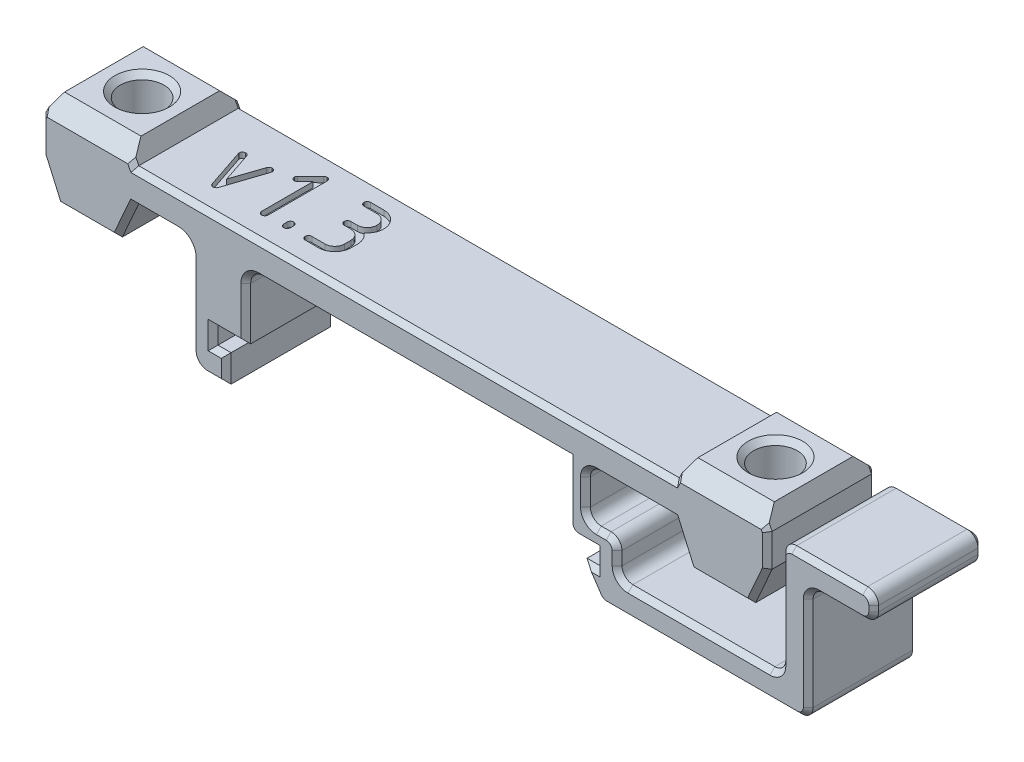
from build123d import *

# Parameters (mm, degrees)
MAIN_BODY_DEPTH         = 5
BOSS_EXTRUDE1_DEPTH     = 5
SKETCH3_R               = 2
CUT_HOLES_DEPTH         = 47.577891751
CUT_EXTRUDE2_DEPTH      = 45.544921147
CUT_EXTRUDE2_DEPTH_BACK = 45.544921147
SKETCH7_W               = 2.9
SKETCH7_H               = 4.4
FILLET_LOWER_EXT_R      = 1.5
FILLET_LOWER_INT_R      = 1.2
FILLET2_R               = 1
CHAMF_FACE_SIZE         = 0.45
CUT_VERSION_DEPTH       = 0.5
CHAMFER1_SIZE           = 0.5
CUT_EXTRUDE3_DEPTH      = 45.544921147


with BuildPart() as part:
    # Sketch1 → main_body (new, symmetric)
    with BuildSketch(Plane.XY):
        Polygon((-17.5, 0), (-17.5, -1.6), (-16.3, -1.6), (-16.3, -4.1), (-19.5, -4.1), (-19.5, 6), (-32.5, 6), (-32.5, 9), (32.5, 9), (32.5, 6), (19.5, 6), (19.5, -1.6), (34.5, -1.6), (34.5, 9), (43, 9), (43, 6.5), (37, 6.5), (37, -4.1), (18, -4.1), (16.3, -1.6), (17.5, -1.6), (17.5, 0), (15, 0), (15, 6), (-14.5, 6), (-14.5, 0), align=None)
    extrude(amount=MAIN_BODY_DEPTH, both=True)

    # Sketch6 → Boss-Extrude1 (add, symmetric)
    with BuildSketch(Plane.XY):
        Polygon((-33.25, 6), (-31.75, 2.6), (-26.25, 2.6), (-24.75, 6), (-24.75, 9), (-25.5, 10.5), (-32.5, 10.5), (-33.25, 9), align=None)
    boss_extrude1 = extrude(amount=BOSS_EXTRUDE1_DEPTH, both=True)

    # Sketch3 → cut_Holes (cut, through all)
    with BuildSketch(Plane(origin=(0, 0, -9.5), x_dir=(1, 0, 0), z_dir=(0, -1, 0))):
        with Locations((-29, 9.5)):
            Circle(SKETCH3_R)
    cut_holes = extrude(amount=-CUT_HOLES_DEPTH, mode=Mode.SUBTRACT)

    # Mirror1: Boss-Extrude1, cut_Holes across plane
    add(boss_extrude1.mirror(Plane(origin=(0, 0, 0), x_dir=(0, 0, 1), z_dir=(1, 0, 0))))
    add(cut_holes.mirror(Plane(origin=(0, 0, 0), x_dir=(0, 0, 1), z_dir=(1, 0, 0))), mode=Mode.SUBTRACT)

    # Sketch7 → Cut-Extrude2 (cut, two sides: drawn at the far end of the back side and taken through both)
    with BuildSketch(Plane.XY.offset(-CUT_EXTRUDE2_DEPTH_BACK)):
        with Locations((18.05, 3.8)):
            Rectangle(SKETCH7_W, SKETCH7_H)
    extrude(amount=CUT_EXTRUDE2_DEPTH + CUT_EXTRUDE2_DEPTH_BACK, mode=Mode.SUBTRACT)

    # fillet_lower_ext
    fillet_lower_ext_edges = [part.edges().sort_by_distance(p)[0] for p in [
        (-19.5, -4.1, 0),
    ]]
    fillet(fillet_lower_ext_edges, radius=FILLET_LOWER_EXT_R)

    # fillet_lower_int
    fillet_lower_int_edges = [part.edges().sort_by_distance(p)[0] for p in [
        (-14.5, 6, 0),
        (-19.5, 6, 0),
    ]]
    fillet(fillet_lower_int_edges, radius=FILLET_LOWER_INT_R)

    # Fillet2
    fillet2_edges = [part.edges().sort_by_distance(p)[0] for p in [
        (16.6, 1.6, 0),
        (16.6, 6, 0),
        (34.5, 9, 0),
        (34.5, -1.6, 0),
        (19.5, -1.6, 0),
        (19.5, 1.6, 0),
        (15, 0, 0),
        (37, 6.5, 0),
        (37, -4.1, 0),
        (18, -4.1, 0),
        (43, 6.5, 0),
        (43, 9, 0),
    ]]
    fillet(fillet2_edges, radius=FILLET2_R)

    # chamf_face
    chamf_face_edges = [part.edges().sort_by_distance(p)[0] for p in [
        (-19.5, 1.1, -5),
        (-17.15, -4.1, -5),
        (-16.3, -2.85, -5),
        (-16.9, -1.6, -5),
        (-17.5, -0.8, -5),
        (-16, 0, -5),
        (-14.5, 2.4, -5),
        (0.85, 6, -5),
        (15, 3.5, -5),
        (16.75, 0, -5),
        (17.5, -0.8, -5),
        (16.9, -1.6, -5),
        (17.001185407, -2.631155011, -5),
        (27.264648658, -4.1, -5),
        (19.5, 0, -5),
        (27.264648658, -4.1, 5),
        (17.001185407, -2.631155011, 5),
        (16.9, -1.6, 5),
        (17.5, -0.8, 5),
        (16.75, 0, 5),
        (15, 3.5, 5),
        (0.85, 6, 5),
        (-14.5, 2.4, 5),
        (-16, 0, 5),
        (-17.5, -0.8, 5),
        (-16.9, -1.6, 5),
        (-16.3, -2.85, 5),
        (-17.15, -4.1, 5),
        (-19.5, 1.1, 5),
        (19.5, 0, 5),
        (-19.060660172, -3.660660172, 5),
        (-19.060660172, -3.660660172, -5),
        (-14.148528137, 5.648528137, 5),
        (-14.148528137, 5.648528137, -5),
        (-22.725, 6, 5),
        (-25.5, 4.3, 5),
        (-29, 2.6, 5),
        (-32.5, 4.3, 5),
        (21.175, 6, 5),
        (32.5, 4.3, 5),
        (29, 2.6, 5),
        (25.5, 4.3, 5),
        (25.5, 4.3, -5),
        (29, 2.6, -5),
        (32.5, 4.3, -5),
        (21.175, 6, -5),
        (-32.5, 4.3, -5),
        (-29, 2.6, -5),
        (-25.5, 4.3, -5),
        (-22.725, 6, -5),
        (-32.875, 9.75, 5),
        (-29, 10.5, 5),
        (-25.125, 9.75, 5),
        (0, 9, 5),
        (25.125, 9.75, 5),
        (29, 10.5, 5),
        (32.875, 9.75, 5),
        (32.875, 9.75, -5),
        (29, 10.5, -5),
        (25.125, 9.75, -5),
        (0, 9, -5),
        (-25.125, 9.75, -5),
        (-29, 10.5, -5),
        (-32.875, 9.75, -5),
        (-33.25, 7.5, 5),
        (33.25, 7.5, 5),
        (33.25, 7.5, -5),
        (-33.25, 7.5, -5),
        (27, -1.6, 5),
        (34.5, 3.7, 5),
        (38.75, 9, 5),
        (43, 7.75, 5),
        (40, 6.5, 5),
        (37, 1.2, 5),
        (37, 1.2, -5),
        (40, 6.5, -5),
        (43, 7.75, -5),
        (38.75, 9, -5),
        (34.5, 3.7, -5),
        (27, -1.6, -5),
        (16.6, 3.8, 5),
        (18.05, 1.6, 5),
        (18.05, 1.6, -5),
        (16.6, 3.8, -5),
        (15.292893219, 0.292893219, 5),
        (16.892893219, 5.707106781, 5),
        (16.892893219, 1.892893219, 5),
        (19.207106781, 1.307106781, 5),
        (19.792893219, -1.307106781, 5),
        (34.207106781, -1.307106781, 5),
        (34.792893219, 8.707106781, 5),
        (42.707106781, 8.707106781, 5),
        (42.707106781, 6.792893219, 5),
        (37.292893219, 6.207106781, 5),
        (36.707106781, -3.807106781, 5),
        (18.061488606, -3.983829741, 5),
        (36.707106781, -3.807106781, -5),
        (37.292893219, 6.207106781, -5),
        (42.707106781, 6.792893219, -5),
        (42.707106781, 8.707106781, -5),
        (34.792893219, 8.707106781, -5),
        (34.207106781, -1.307106781, -5),
        (19.792893219, -1.307106781, -5),
        (19.207106781, 1.307106781, -5),
        (16.892893219, 1.892893219, -5),
        (16.892893219, 5.707106781, -5),
        (15.292893219, 0.292893219, -5),
        (18.061488606, -3.983829741, -5),
        (-19.851471863, 5.648528137, 5),
        (-19.851471863, 5.648528137, -5),
    ]]
    chamfer(chamf_face_edges, length=CHAMF_FACE_SIZE)

    # Sketch4 → cut_version (cut)
    with BuildSketch(Plane(origin=(0, 9, 0), x_dir=(1, 0, 0), z_dir=(0, 1, 0))):
        with BuildLine():
            add(Edge.make_bspline(
                [(-21.180476134, 1.074905685), (-21.178229692, 1.055475579), (-21.173879093, 1.017846026), (-21.161688752, 0.981990729), (-21.155792921, 0.964649396)],
                knots=[0, 0, 0, 0, 1.032704525, 2, 2, 2, 2], degree=3))
            Line((-21.155792921, 0.964649396), (-19.95821289, -2.616713742))
            add(Edge.make_bspline(
                [(-19.95821289, -2.616713742), (-19.945122381, -2.648127203), (-19.920205519, -2.707920514), (-19.852245155, -2.776643503), (-19.768521194, -2.823749577), (-19.704805806, -2.832181772), (-19.671646579, -2.836570116)],
                knots=[0, 0, 0, 0, 1.054683453, 2.007515722, 2.96305683, 4, 4, 4, 4], degree=3))
            add(Edge.make_bspline(
                [(-19.671646579, -2.836570116), (-19.636883169, -2.832254713), (-19.570839873, -2.824056339), (-19.484084239, -2.777440659), (-19.41591287, -2.707903707), (-19.390878095, -2.64831818), (-19.37774414, -2.617057921)],
                knots=[0, 0, 0, 0, 1.06836729, 2.029677035, 2.966312611, 4, 4, 4, 4], degree=3))
            Line((-19.37774414, -2.617057921), (-18.179609137, 0.965586658))
            add(Edge.make_bspline(
                [(-18.179609137, 0.965586658), (-18.175165622, 0.982665802), (-18.165880697, 1.01835344), (-18.164059576, 1.055195206), (-18.163109994, 1.074405494)],
                knots=[0, 0, 0, 0, 0.957146177, 2, 2, 2, 2], degree=3))
            add(Edge.make_bspline(
                [(-18.163109994, 1.074405494), (-18.164733377, 1.094475764), (-18.167875161, 1.133318403), (-18.186175558, 1.188545541), (-18.212592243, 1.239471456), (-18.25110866, 1.282952891), (-18.296384686, 1.319665958), (-18.347492654, 1.34864997), (-18.405776221, 1.364210818), (-18.445958207, 1.367713434), (-18.466768531, 1.369527445)],
                knots=[0, 0, 0, 0, 1.027789528, 1.989114056, 2.957849911, 3.946954469, 4.938684973, 5.935646619, 6.930867606, 8, 8, 8, 8], degree=3))
            add(Edge.make_bspline(
                [(-18.466768531, 1.369527445), (-18.499846403, 1.365007685), (-18.563213413, 1.356349216), (-18.648157394, 1.311071016), (-18.714802614, 1.240873743), (-18.740128103, 1.181186085), (-18.753353896, 1.15001525)],
                knots=[0, 0, 0, 0, 1.03692919, 1.986436811, 2.948451835, 4, 4, 4, 4], degree=3))
            Line((-18.753353896, 1.15001525), (-19.671613233, -1.58238757))
            Line((-19.671613233, -1.58238757), (-20.581988614, 1.150588087))
            add(Edge.make_bspline(
                [(-20.581988614, 1.150588087), (-20.59544029, 1.181576306), (-20.621338409, 1.241237019), (-20.689349611, 1.311524093), (-20.777309264, 1.356697902), (-20.843044194, 1.365094877), (-20.87774414, 1.369527445)],
                knots=[0, 0, 0, 0, 1.028913269, 1.980936724, 2.934183284, 4, 4, 4, 4], degree=3))
            add(Edge.make_bspline(
                [(-20.87774414, 1.369527445), (-20.897743404, 1.367694972), (-20.936718664, 1.364123785), (-20.993718481, 1.348424285), (-21.04461462, 1.319346986), (-21.09095554, 1.283043392), (-21.13053148, 1.239514385), (-21.158550939, 1.188871734), (-21.176563528, 1.133281068), (-21.179754091, 1.094463045), (-21.181402677, 1.074405494)],
                knots=[0, 0, 0, 0, 1.030543514, 2.008358934, 3.007991962, 4.018680577, 5.024181706, 6.005556065, 6.969456486, 8, 8, 8, 8], degree=3))
            Line((-21.181402677, 1.074405494), (-21.180476134, 1.074905685))
        make_face()
        with BuildLine():
            add(Edge.make_bspline(
                [(-16.638972227, 1.888665688), (-16.652972987, 1.874710807), (-16.680696441, 1.847078199), (-16.710474368, 1.795810047), (-16.727632283, 1.738054778), (-16.730922833, 1.697690205), (-16.732622189, 1.676844518)],
                knots=[0, 0, 0, 0, 0.992164211, 1.96462331, 2.948859839, 4, 4, 4, 4], degree=3))
            add(Edge.make_bspline(
                [(-16.732622189, 1.676844518), (-16.730982583, 1.655972744), (-16.727807729, 1.615557655), (-16.709839194, 1.558198421), (-16.683190497, 1.50569602), (-16.644579553, 1.461233708), (-16.600112944, 1.422596701), (-16.547601722, 1.396046709), (-16.490325151, 1.377710353), (-16.449846912, 1.375530242), (-16.428963653, 1.374405494)],
                knots=[0, 0, 0, 0, 1.0530203, 2.0390173, 3.01127151, 4.001099292, 4.990927074, 5.963181283, 6.949178283, 8, 8, 8, 8], degree=3))
            add(Edge.make_bspline(
                [(-16.428963653, 1.374405494), (-16.407279145, 1.376479493), (-16.365196389, 1.380504467), (-16.30599893, 1.399127939), (-16.252991635, 1.427412629), (-16.224003518, 1.453827921), (-16.209451457, 1.467088421)],
                knots=[0, 0, 0, 0, 1.06971459, 2.075976935, 3.034138695, 4, 4, 4, 4], degree=3))
            Line((-16.209451457, 1.467088421), (-15.513393435, 2.179439555))
            Line((-15.513393435, 2.179439555), (-15.513393435, -2.532622183))
            add(Edge.make_bspline(
                [(-15.513393435, -2.532622183), (-15.512151243, -2.553595292), (-15.509749357, -2.594148622), (-15.491554772, -2.651609659), (-15.464778743, -2.703612611), (-15.42760543, -2.748966042), (-15.383161366, -2.786700972), (-15.331855902, -2.81384126), (-15.275625191, -2.831742741), (-15.236012074, -2.834925823), (-15.215549018, -2.836570116)],
                knots=[0, 0, 0, 0, 1.064897874, 2.059072668, 3.039390689, 4.024276954, 5.022314302, 5.984364611, 6.958777708, 8, 8, 8, 8], degree=3))
            add(Edge.make_bspline(
                [(-15.215549018, -2.836570116), (-15.195101611, -2.834874744), (-15.155130709, -2.831560606), (-15.098330278, -2.81412534), (-15.046758765, -2.786658458), (-15.002140453, -2.74903438), (-14.965458394, -2.703236043), (-14.936413751, -2.652203257), (-14.920869107, -2.593899598), (-14.917364211, -2.553720439), (-14.915549018, -2.532911579)],
                knots=[0, 0, 0, 0, 1.038553346, 2.030179789, 2.989764092, 3.985243189, 4.967604913, 5.955148361, 6.940967594, 8, 8, 8, 8], degree=3))
            Line((-14.915549018, -2.532911579), (-14.915549018, 2.864107523))
            add(Edge.make_bspline(
                [(-14.915549018, 2.864107523), (-14.917412723, 2.884276544), (-14.921065093, 2.923802521), (-14.936389847, 2.981522331), (-14.965522014, 3.032461712), (-15.001748929, 3.078401203), (-15.047188141, 3.11463771), (-15.098283655, 3.142192757), (-15.155068403, 3.159918834), (-15.195094906, 3.162242472), (-15.215549018, 3.163429884)],
                knots=[0, 0, 0, 0, 1.033276339, 2.024949948, 3.018358012, 4.006553579, 4.994749146, 5.960032027, 6.957547333, 8, 8, 8, 8], degree=3))
            add(Edge.make_bspline(
                [(-15.215549018, 3.163429884), (-15.235998424, 3.162242575), (-15.275626754, 3.159941722), (-15.332169152, 3.142454949), (-15.381909564, 3.112567948), (-15.409139042, 3.08557452), (-15.422866092, 3.07196647)],
                knots=[0, 0, 0, 0, 1.049879887, 2.034532876, 3.009159723, 4, 4, 4, 4], degree=3))
            Line((-15.422866092, 3.07196647), (-16.638972227, 1.888665688))
        make_face()
        with BuildLine():
            add(Edge.make_bspline(
                [(-13.497056259, -2.521145192), (-13.495982099, -2.542277246), (-13.493892454, -2.583387053), (-13.475941144, -2.64152942), (-13.448654902, -2.694363881), (-13.410933087, -2.740056115), (-13.365563943, -2.778316986), (-13.313518492, -2.806964482), (-13.255254137, -2.824463441), (-13.214448803, -2.826826194), (-13.193597799, -2.82803353)],
                knots=[0, 0, 0, 0, 1.053795159, 2.050028647, 3.013195991, 4.009429478, 4.990006149, 5.962765968, 6.958999455, 8, 8, 8, 8], degree=3))
            add(Edge.make_bspline(
                [(-13.193597799, -2.82803353), (-13.172732509, -2.826876707), (-13.132289099, -2.824634423), (-13.074579668, -2.806682737), (-13.022844318, -2.778342006), (-12.977482987, -2.740049332), (-12.939763382, -2.694365373), (-12.912460696, -2.641529981), (-12.894651849, -2.583629929), (-12.892340066, -2.542799696), (-12.891158775, -2.521935969)],
                knots=[0, 0, 0, 0, 1.045213593, 2.025948432, 3.002645121, 3.987190297, 4.987455656, 5.954521048, 6.954786407, 8, 8, 8, 8], degree=3))
            Line((-12.891158775, -2.521935969), (-12.890139339, -2.22278153))
            add(Edge.make_bspline(
                [(-12.890139339, -2.22278153), (-12.891718256, -2.20123099), (-12.894786282, -2.159355715), (-12.91249375, -2.10001714), (-12.939080044, -2.04619233), (-12.977611837, -2.001383115), (-13.022878158, -1.964154607), (-13.074906494, -1.937414214), (-13.132250718, -1.919160982), (-13.172719447, -1.916969185), (-13.193597799, -1.915838408)],
                knots=[0, 0, 0, 0, 1.076562654, 2.091889952, 3.072719245, 4.052917712, 5.020200157, 5.982996012, 6.959400964, 8, 8, 8, 8], degree=3))
            add(Edge.make_bspline(
                [(-13.193597799, -1.915838408), (-13.214461887, -1.917019718), (-13.255292825, -1.919331536), (-13.313187815, -1.937140129), (-13.365530821, -1.964179756), (-13.410800766, -2.001376687), (-13.449351584, -2.046192455), (-13.475856894, -2.100023176), (-13.493911976, -2.159415947), (-13.496118499, -2.201469658), (-13.497256335, -2.223155482)],
                knots=[0, 0, 0, 0, 1.037498569, 2.03038068, 2.990307883, 3.954708309, 4.931986273, 5.909893183, 6.922195311, 8, 8, 8, 8], degree=3))
            Line((-13.497256335, -2.223155482), (-13.497056259, -2.521145192))
        make_face()
        with BuildLine():
            add(Edge.make_bspline(
                [(-10.028271722, 0.134360477), (-9.96637049, 0.130053792), (-9.846068702, 0.121683976), (-9.674241364, 0.071470496), (-9.51935378, -0.008517443), (-9.38519772, -0.118149917), (-9.273199343, -0.249335082), (-9.191879788, -0.401669705), (-9.138341017, -0.570104911), (-9.130530421, -0.689004927), (-9.126524628, -0.74998475)],
                knots=[0, 0, 0, 0, 1.058978584, 2.058069159, 3.037758071, 4.021657752, 5.003688209, 5.968206507, 6.9579614, 8, 8, 8, 8], degree=3))
            Line((-9.126524628, -0.74998475), (-9.126325743, -1.33592225))
            add(Edge.make_bspline(
                [(-9.126325743, -1.33592225), (-9.130385696, -1.397123472), (-9.138287906, -1.51624428), (-9.192094088, -1.685181029), (-9.273434943, -1.838579367), (-9.385146593, -1.971789808), (-9.518545447, -2.084425895), (-9.674547801, -2.16365083), (-9.846022141, -2.216099273), (-9.966779114, -2.223976899), (-10.028963653, -2.22803353)],
                knots=[0, 0, 0, 0, 1.041256597, 2.026680567, 2.993073191, 3.981435433, 4.969797675, 5.945199709, 6.941868068, 8, 8, 8, 8], degree=3))
            Line((-10.028963653, -2.22803353), (-11.233676162, -2.22803353))
            add(Edge.make_bspline(
                [(-11.233676162, -2.22803353), (-11.254613596, -2.229176859), (-11.295535389, -2.23141147), (-11.353060542, -2.24964611), (-11.406143357, -2.274872722), (-11.450613737, -2.312388371), (-11.489260154, -2.355599128), (-11.515847579, -2.406914912), (-11.53432882, -2.463376797), (-11.536414009, -2.503482762), (-11.537500238, -2.524374994)],
                knots=[0, 0, 0, 0, 1.060955747, 2.073616602, 3.043257174, 4.026868974, 5.007876325, 5.968681719, 6.941833903, 8, 8, 8, 8], degree=3))
            add(Edge.make_bspline(
                [(-11.537500238, -2.524374994), (-11.536324954, -2.545243955), (-11.534024927, -2.586084432), (-11.516131744, -2.643910995), (-11.489282847, -2.696735901), (-11.45068042, -2.741213713), (-11.406202609, -2.779816139), (-11.353377703, -2.806665037), (-11.29555114, -2.824558219), (-11.254710663, -2.826858246), (-11.233841701, -2.82803353)],
                knots=[0, 0, 0, 0, 1.045974665, 2.046968367, 3.014737927, 4, 4.985262073, 5.953031633, 6.954025335, 8, 8, 8, 8], degree=3))
            Line((-11.233841701, -2.82803353), (-10.028271722, -2.82803353))
            add(Edge.make_bspline(
                [(-10.028271722, -2.82803353), (-9.975976985, -2.825782366), (-9.87310357, -2.82135391), (-9.722235502, -2.797587267), (-9.578192155, -2.76103724), (-9.440884971, -2.712238134), (-9.310748227, -2.650670609), (-9.18673035, -2.577202364), (-9.069213281, -2.490433373), (-8.960723561, -2.390598278), (-8.860520845, -2.282603134), (-8.772569641, -2.166671084), (-8.697652424, -2.044162297), (-8.636273715, -1.914883454), (-8.587619732, -1.779181971), (-8.550844615, -1.63723296), (-8.527141666, -1.488955702), (-8.522687775, -1.387876129), (-8.520427067, -1.336570116)],
                knots=[0, 0, 0, 0, 1.066873082, 2.098736551, 3.10817358, 4.094186606, 5.065874226, 6.03985819, 7.029802135, 8.039239164, 9.0425632, 10.030839284, 11.001996208, 11.966191853, 12.944401058, 13.937776121, 14.953255501, 16, 16, 16, 16], degree=3))
            Line((-8.520427067, -1.336570116), (-8.519408822, -0.749441686))
            add(Edge.make_bspline(
                [(-8.519408822, -0.749441686), (-8.521534565, -0.690941981), (-8.525747682, -0.574998463), (-8.557773582, -0.404707402), (-8.606154932, -0.239925138), (-8.675008622, -0.082519878), (-8.760803818, 0.066371385), (-8.866304358, 0.202681098), (-8.98692394, 0.3286591), (-9.079607787, 0.400323754), (-9.126524628, 0.436600616)],
                knots=[0, 0, 0, 0, 1.014332037, 2.010355889, 2.996594147, 3.98838943, 4.983888816, 5.969874884, 6.972344594, 8, 8, 8, 8], degree=3))
            add(Edge.make_bspline(
                [(-9.126524628, 0.436600616), (-9.079588122, 0.474110019), (-8.986769312, 0.548286357), (-8.866213049, 0.677932272), (-8.760709649, 0.817907015), (-8.67527803, 0.970166419), (-8.606076133, 1.13022348), (-8.55785164, 1.297461759), (-8.525523998, 1.469909408), (-8.522133964, 1.587266783), (-8.520427067, 1.646356714)],
                knots=[0, 0, 0, 0, 1.026490339, 2.029925523, 3.018678281, 4.018251485, 5.008860598, 5.994552535, 6.99024878, 8, 8, 8, 8], degree=3))
            add(Edge.make_bspline(
                [(-8.520427067, 1.646356714), (-8.522682269, 1.698882312), (-8.527126357, 1.802388956), (-8.550920165, 1.954275121), (-8.58715839, 2.099241103), (-8.636561585, 2.237126762), (-8.697630487, 2.368508858), (-8.772176783, 2.493336147), (-8.860590432, 2.610567944), (-8.960274513, 2.719920082), (-9.069607853, 2.819645772), (-9.186675626, 2.907667569), (-9.310424581, 2.982563513), (-9.440921476, 3.043909524), (-9.578182059, 3.09279368), (-9.722238309, 3.129318943), (-9.873330631, 3.153133175), (-9.976437228, 3.157530952), (-10.028963653, 3.159771348)],
                knots=[0, 0, 0, 0, 1.062461703, 2.093680967, 3.102508552, 4.080142263, 5.051013382, 6.027990232, 7.014431632, 8.015290284, 9.016148936, 10.002590336, 10.97252138, 11.935951425, 12.913585136, 13.914443788, 14.937538297, 16, 16, 16, 16], degree=3))
            Line((-10.028963653, 3.159771348), (-11.233676162, 3.160788402))
            add(Edge.make_bspline(
                [(-11.233676162, 3.160788402), (-11.254591568, 3.159188976), (-11.295436232, 3.156065535), (-11.35338468, 3.138467904), (-11.406200729, 3.111536429), (-11.450680928, 3.072956264), (-11.489282714, 3.028472477), (-11.516131781, 2.975649153), (-11.534024917, 2.917822159), (-11.53632495, 2.876981742), (-11.537500238, 2.856112811)],
                knots=[0, 0, 0, 0, 1.049928132, 2.050352754, 3.017572123, 4.002274059, 4.986975996, 5.954195365, 6.954619987, 8, 8, 8, 8], degree=3))
            add(Edge.make_bspline(
                [(-11.537500238, 2.856112811), (-11.536375481, 2.83522956), (-11.534195352, 2.794751337), (-11.515859123, 2.737474653), (-11.489308657, 2.684963851), (-11.450673449, 2.640495648), (-11.406204437, 2.601890642), (-11.353377201, 2.575042427), (-11.295551274, 2.557149059), (-11.254710708, 2.554849058), (-11.233841701, 2.553673787)],
                knots=[0, 0, 0, 0, 1.048536336, 2.03238894, 3.002528642, 3.990203696, 4.97787875, 5.948018452, 6.951463664, 8, 8, 8, 8], degree=3))
            Line((-11.233841701, 2.553673787), (-10.028271722, 2.553871481))
            add(Edge.make_bspline(
                [(-10.028271722, 2.553871481), (-9.966293971, 2.549820462), (-9.845611632, 2.541932367), (-9.674453953, 2.487974476), (-9.518447893, 2.407580406), (-9.385125164, 2.293690334), (-9.273037498, 2.159084891), (-9.191862675, 2.003057374), (-9.138217645, 1.830656601), (-9.130496554, 1.708960354), (-9.126524628, 1.646356714)],
                knots=[0, 0, 0, 0, 1.045582401, 2.035945591, 3.006428587, 3.990968025, 4.976416705, 5.9468997, 6.943833046, 8, 8, 8, 8], degree=3))
            add(Edge.make_bspline(
                [(-9.126524628, 1.646356714), (-9.130541621, 1.584576931), (-9.13837467, 1.464107683), (-9.191753789, 1.293174937), (-9.27380147, 1.138239893), (-9.384587119, 1.002596627), (-9.518854205, 0.889096088), (-9.674063437, 0.80681618), (-9.845949935, 0.753486858), (-9.966780321, 0.744753585), (-10.028963653, 0.740259153)],
                knots=[0, 0, 0, 0, 1.044240831, 2.036247155, 3.002264277, 3.994675749, 4.98084866, 5.956171723, 6.948178046, 8, 8, 8, 8], degree=3))
            Line((-10.028963653, 0.740259153), (-10.626759241, 0.741277398))
            add(Edge.make_bspline(
                [(-10.626759241, 0.741277398), (-10.64796567, 0.739751559), (-10.688730379, 0.736818469), (-10.746389695, 0.718680977), (-10.798889701, 0.692050318), (-10.843367528, 0.653437598), (-10.881945034, 0.608959852), (-10.908893018, 0.556144944), (-10.92641059, 0.49823452), (-10.929713306, 0.457458127), (-10.931402677, 0.436600616)],
                knots=[0, 0, 0, 0, 1.064044783, 2.045392747, 3.013062719, 3.998223403, 4.983384088, 5.95105406, 6.951944754, 8, 8, 8, 8], degree=3))
            add(Edge.make_bspline(
                [(-10.931402677, 0.436600616), (-10.929763071, 0.415728842), (-10.926588217, 0.375313753), (-10.908619682, 0.317954519), (-10.881970985, 0.265452118), (-10.843360041, 0.220989805), (-10.798893432, 0.182352799), (-10.74638221, 0.155802807), (-10.689105639, 0.137466451), (-10.648627399, 0.13528634), (-10.62774414, 0.134161592)],
                knots=[0, 0, 0, 0, 1.0530203, 2.0390173, 3.01127151, 4.001099292, 4.990927074, 5.963181283, 6.949178283, 8, 8, 8, 8], degree=3))
            Line((-10.62774414, 0.134161592), (-10.028271722, 0.134360477))
        make_face()
    extrude(amount=-CUT_VERSION_DEPTH, mode=Mode.SUBTRACT)

    # Chamfer1
    chamfer1_edges = [part.edges().sort_by_distance(p)[0] for p in [
        (31, 10.5, 0),
        (-31, 10.5, 0),
    ]]
    chamfer(chamfer1_edges, length=CHAMFER1_SIZE)

    # Sketch8 → Cut-Extrude3 (cut, symmetric)
    with BuildSketch(Plane(origin=(0, 0, 0), x_dir=(0, 0, -1), z_dir=(1, 0, 0))):
        Polygon((3.6, 10.5), (5, 9.1), (5, 10.5), align=None)
    cut_extrude3 = extrude(amount=CUT_EXTRUDE3_DEPTH, both=True, mode=Mode.SUBTRACT)

    # Mirror2: Cut-Extrude3 across plane
    add(cut_extrude3.mirror(Plane.XY), mode=Mode.SUBTRACT)


solid = part.part
